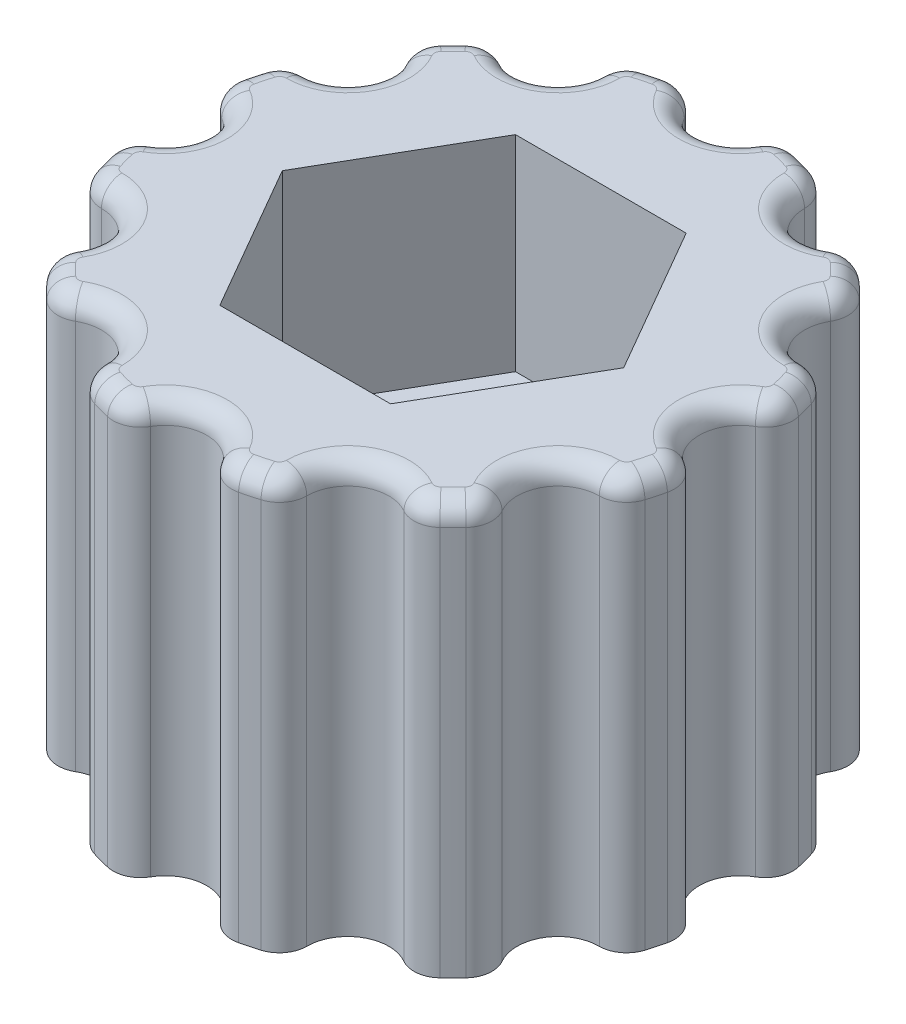
from build123d import *

# Parameters (mm, degrees)
SKETCH1_R                = 7
BODY_DEPTH               = 10
MOUNTING_HOLE_REACH      = 12
SKETCH2_R                = 2.2
NUT_COUNTERBORE_DEPTH    = 5
KNURL_CUTTING_TOOL_DEPTH = 11
FILLET1_R                = 0.5


with BuildPart() as part:
    # Sketch1 → Body (new body)
    with BuildSketch(Plane(origin=(0, 0, 0), x_dir=(1, 0, 0), z_dir=(0, 1, 0))):
        Circle(SKETCH1_R)
    extrude(amount=BODY_DEPTH)

    # Sketch2 → Mounting Hole (cut, up to next)
    with BuildSketch(Plane(origin=(0, 10, 0), x_dir=(1, 0, 0), z_dir=(0, 1, 0)), mode=Mode.PRIVATE) as mounting_hole_sk1:
        Circle(SKETCH2_R)
    mounting_hole_tool1 = extrude(mounting_hole_sk1.sketch, amount=-MOUNTING_HOLE_REACH, mode=Mode.PRIVATE) & part.part
    add(mounting_hole_tool1.solids().sort_by_distance((0, 10, 0))[0], mode=Mode.SUBTRACT)

    # Sketch3 → Nut Counterbore (cut)
    with BuildSketch(Plane(origin=(0, 10, 0), x_dir=(1, 0, 0), z_dir=(0, 1, 0))):
        Polygon((2.078460969, 3.6), (-2.078460969, 3.6), (-4.156921938, 0), (-2.078460969, -3.6), (2.078460969, -3.6), (4.156921938, 0), align=None)
    extrude(amount=-NUT_COUNTERBORE_DEPTH, mode=Mode.SUBTRACT)

    # Sketch5 → Knurl Cutting Tool (cut, through all)
    with BuildSketch(Plane(origin=(0, 10, 0), x_dir=(1, 0, 0), z_dir=(0, 1, 0))):
        with BuildLine():
            ThreePointArc((-0.866025404, 6.5), (0, 6), (0.866025404, 6.5))
            ThreePointArc((0.866025404, 6.5), (1.178469202, 6.778441957), (1.595309954, 6.815789474))
            ThreePointArc((1.595309954, 6.815789474), (0, 7), (-1.595309954, 6.815789474))
            ThreePointArc((-1.595309954, 6.815789474), (-1.178469202, 6.778441957), (-0.866025404, 6.5))
        make_face()
        with BuildLine():
            ThreePointArc((2.5, 6.062177826), (3, 5.196152423), (4, 5.196152423))
            ThreePointArc((4, 5.196152423), (4.409805245, 5.281068332), (4.789473684, 5.104991854))
            ThreePointArc((4.789473684, 5.104991854), (3.5, 6.062177826), (2.026315789, 6.700301808))
            ThreePointArc((2.026315789, 6.700301808), (2.368636712, 6.459537534), (2.5, 6.062177826))
        make_face()
        with BuildLine():
            ThreePointArc((5.196152423, 4), (5.196152423, 3), (6.062177826, 2.5))
            ThreePointArc((6.062177826, 2.5), (6.459537534, 2.368636712), (6.700301808, 2.026315789))
            ThreePointArc((6.700301808, 2.026315789), (6.062177826, 3.5), (5.104991854, 4.789473684))
            ThreePointArc((5.104991854, 4.789473684), (5.281068332, 4.409805245), (5.196152423, 4))
        make_face()
        with BuildLine():
            ThreePointArc((6.5, 0.866025404), (6, 0), (6.5, -0.866025404))
            ThreePointArc((6.5, -0.866025404), (6.778441957, -1.178469202), (6.815789474, -1.595309954))
            ThreePointArc((6.815789474, -1.595309954), (7, 0), (6.815789474, 1.595309954))
            ThreePointArc((6.815789474, 1.595309954), (6.778441957, 1.178469202), (6.5, 0.866025404))
        make_face()
        with BuildLine():
            ThreePointArc((6.062177826, -2.5), (5.196152423, -3), (5.196152423, -4))
            ThreePointArc((5.196152423, -4), (5.281068332, -4.409805245), (5.104991854, -4.789473684))
            ThreePointArc((5.104991854, -4.789473684), (6.062177826, -3.5), (6.700301808, -2.026315789))
            ThreePointArc((6.700301808, -2.026315789), (6.459537534, -2.368636712), (6.062177826, -2.5))
        make_face()
        with BuildLine():
            ThreePointArc((4, -5.196152423), (3, -5.196152423), (2.5, -6.062177826))
            ThreePointArc((2.5, -6.062177826), (2.368636712, -6.459537534), (2.026315789, -6.700301808))
            ThreePointArc((2.026315789, -6.700301808), (3.5, -6.062177826), (4.789473684, -5.104991854))
            ThreePointArc((4.789473684, -5.104991854), (4.409805245, -5.281068332), (4, -5.196152423))
        make_face()
        with BuildLine():
            ThreePointArc((0.866025404, -6.5), (0, -6), (-0.866025404, -6.5))
            ThreePointArc((-0.866025404, -6.5), (-1.178469202, -6.778441957), (-1.595309954, -6.815789474))
            ThreePointArc((-1.595309954, -6.815789474), (0, -7), (1.595309954, -6.815789474))
            ThreePointArc((1.595309954, -6.815789474), (1.178469202, -6.778441957), (0.866025404, -6.5))
        make_face()
        with BuildLine():
            ThreePointArc((-2.5, -6.062177826), (-3, -5.196152423), (-4, -5.196152423))
            ThreePointArc((-4, -5.196152423), (-4.409805245, -5.281068332), (-4.789473684, -5.104991854))
            ThreePointArc((-4.789473684, -5.104991854), (-3.5, -6.062177826), (-2.026315789, -6.700301808))
            ThreePointArc((-2.026315789, -6.700301808), (-2.368636712, -6.459537534), (-2.5, -6.062177826))
        make_face()
        with BuildLine():
            ThreePointArc((-5.196152423, -4), (-5.196152423, -3), (-6.062177826, -2.5))
            ThreePointArc((-6.062177826, -2.5), (-6.459537534, -2.368636712), (-6.700301808, -2.026315789))
            ThreePointArc((-6.700301808, -2.026315789), (-6.062177826, -3.5), (-5.104991854, -4.789473684))
            ThreePointArc((-5.104991854, -4.789473684), (-5.281068332, -4.409805245), (-5.196152423, -4))
        make_face()
        with BuildLine():
            ThreePointArc((-6.5, -0.866025404), (-6, 0), (-6.5, 0.866025404))
            ThreePointArc((-6.5, 0.866025404), (-6.778441957, 1.178469202), (-6.815789474, 1.595309954))
            ThreePointArc((-6.815789474, 1.595309954), (-7, 0), (-6.815789474, -1.595309954))
            ThreePointArc((-6.815789474, -1.595309954), (-6.778441957, -1.178469202), (-6.5, -0.866025404))
        make_face()
        with BuildLine():
            ThreePointArc((-6.062177826, 2.5), (-5.196152423, 3), (-5.196152423, 4))
            ThreePointArc((-5.196152423, 4), (-5.281068332, 4.409805245), (-5.104991854, 4.789473684))
            ThreePointArc((-5.104991854, 4.789473684), (-6.062177826, 3.5), (-6.700301808, 2.026315789))
            ThreePointArc((-6.700301808, 2.026315789), (-6.459537534, 2.368636712), (-6.062177826, 2.5))
        make_face()
        with BuildLine():
            ThreePointArc((-4, 5.196152423), (-3, 5.196152423), (-2.5, 6.062177826))
            ThreePointArc((-2.5, 6.062177826), (-2.368636712, 6.459537534), (-2.026315789, 6.700301808))
            ThreePointArc((-2.026315789, 6.700301808), (-3.5, 6.062177826), (-4.789473684, 5.104991854))
            ThreePointArc((-4.789473684, 5.104991854), (-4.409805245, 5.281068332), (-4, 5.196152423))
        make_face()
    extrude(amount=-KNURL_CUTTING_TOOL_DEPTH, mode=Mode.SUBTRACT)

    # Fillet1
    fillet1_edges = [part.edges().sort_by_distance(p)[0] for p in [
        (1.178469202, 10, 6.778441957),
        (0, 10, 6),
        (-1.178469202, 10, 6.778441957),
        (4.409805245, 10, 5.281068332),
        (3, 10, 5.196152423),
        (2.368636712, 10, 6.459537534),
        (6.459537534, 10, 2.368636712),
        (5.196152423, 10, 3),
        (5.281068332, 10, 4.409805245),
        (6.778441957, 10, -1.178469202),
        (6, 10, 0),
        (6.778441957, 10, 1.178469202),
        (5.281068332, 10, -4.409805245),
        (5.196152423, 10, -3),
        (6.459537534, 10, -2.368636712),
        (2.368636712, 10, -6.459537534),
        (3, 10, -5.196152423),
        (4.409805245, 10, -5.281068332),
        (-6.778441957, 10, 1.178469202),
        (-6, 10, 0),
        (-6.778441957, 10, -1.178469202),
        (-6.459537534, 10, -2.368636712),
        (-5.196152423, 10, -3),
        (-5.281068332, 10, -4.409805245),
        (-4.409805245, 10, -5.281068332),
        (-3, 10, -5.196152423),
        (-2.368636712, 10, -6.459537534),
        (-1.178469202, 10, -6.778441957),
        (0, 10, -6),
        (1.178469202, 10, -6.778441957),
        (1.811733316, 10, 6.761480784),
        (4.949747468, 10, 4.949747468),
        (6.761480784, 10, 1.811733316),
        (6.761480784, 10, -1.811733316),
        (4.949747468, 10, -4.949747468),
        (1.811733316, 10, -6.761480784),
        (-1.811733316, 10, -6.761480784),
        (-4.949747468, 10, -4.949747468),
        (-6.761480784, 10, -1.811733316),
        (-6.761480784, 10, 1.811733316),
        (-4.949747468, 10, 4.949747468),
        (-1.811733316, 10, 6.761480784),
        (-5.281068332, 10, 4.409805245),
        (-5.196152423, 10, 3),
        (-6.459537534, 10, 2.368636712),
        (-2.368636712, 10, 6.459537534),
        (-3, 10, 5.196152423),
        (-4.409805245, 10, 5.281068332),
    ]]
    fillet(fillet1_edges, radius=FILLET1_R)


solid = part.part
